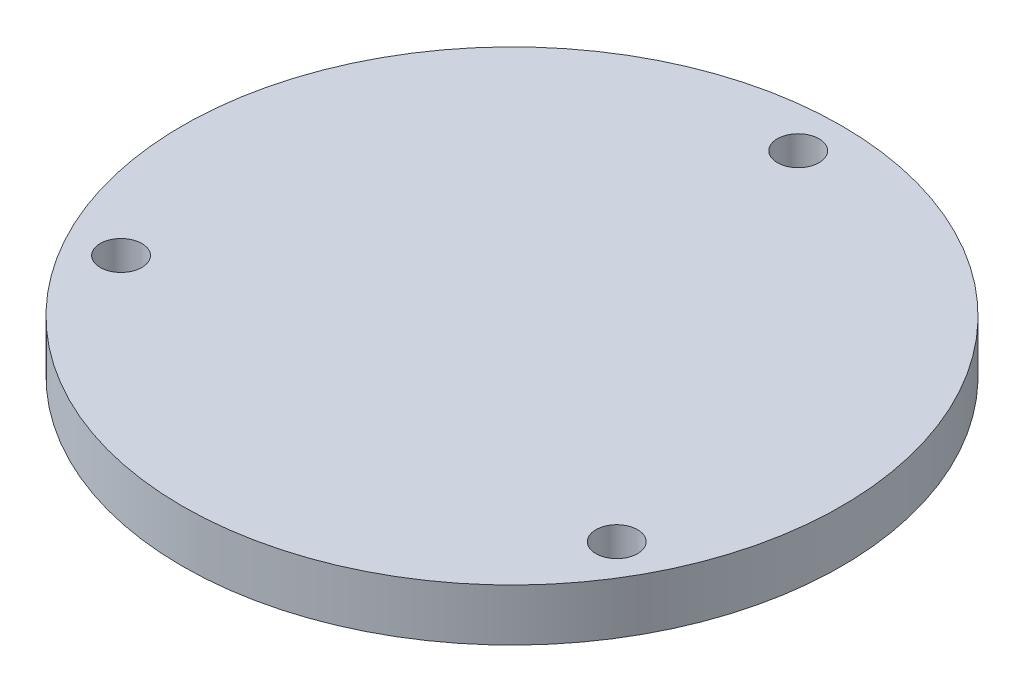
from build123d import *

# Parameters (mm, degrees)
SKETCH_1_R         = 19
EXTRUDE_1_DEPTH    = 3
HOLE_WIZARD_M2_1_D = 2.4


with BuildPart() as part:
    # 스케치1 → 보스-돌출1 (new body)
    with BuildSketch(Plane(origin=(0, 0, 0), x_dir=(1, 0, 0), z_dir=(0, 1, 0))):
        Circle(SKETCH_1_R)
    extrude(amount=EXTRUDE_1_DEPTH)

    # M2 여유 구멍1 (through all)
    with Locations(Plane(origin=(0, 3, 0), x_dir=(1, 0, 0), z_dir=(0, 1, 0))):
        with Locations((14.289419162, -8.25), (0, 16.5), (-14.289419162, -8.25)):
            Hole(HOLE_WIZARD_M2_1_D / 2)


solid = part.part
